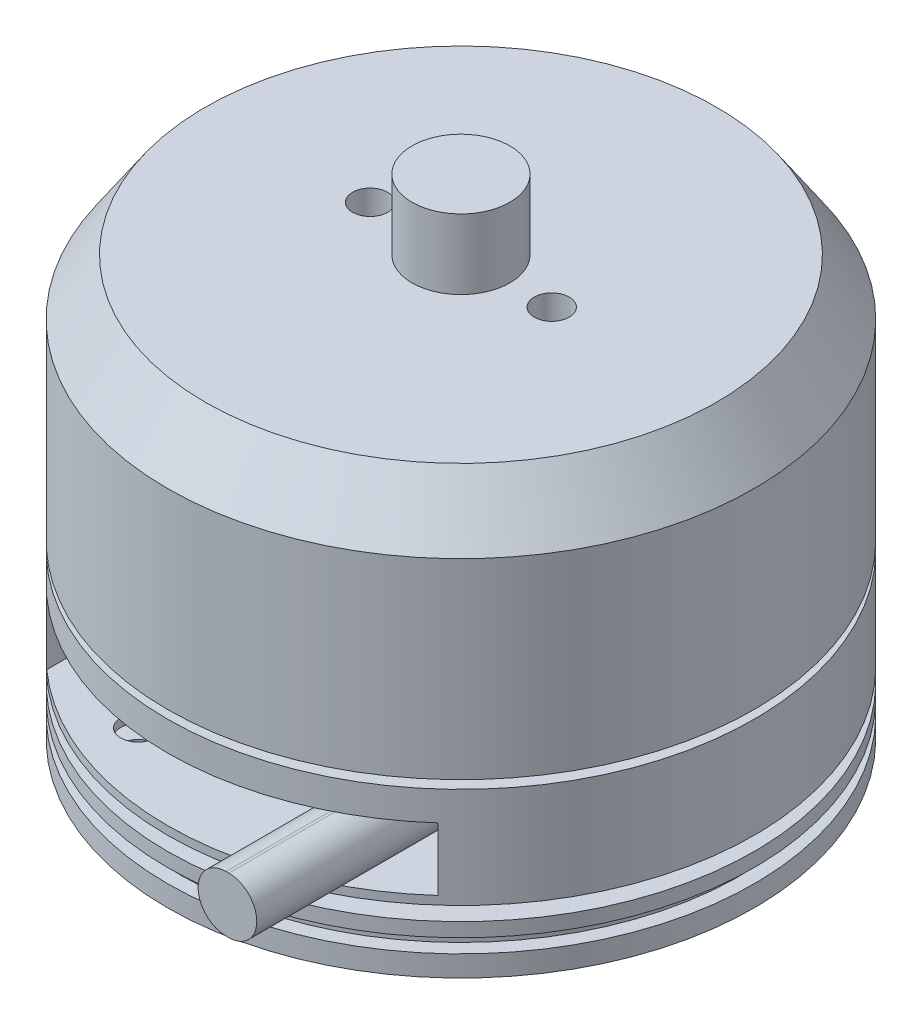
from build123d import *

# Parameters (mm, degrees)
SKETCH_2_W               = 28
SKETCH_2_H               = 4.5
CUT_EXTRUDE_1_DEPTH      = 10
EXTRUDE_1_DEPTH          = 15
HOLE_WIZARD_M3_1_D       = 2.5
HOLE_WIZARD_M3_1_DEPTH   = 4
HOLE_WIZARD_M3_1_TIP     = 0.751075774
CUT_EXTRUDE_2_DEPTH      = 20
HOLE_WIZARD_M4_1_D       = 3.3
HOLE_WIZARD_M4_1_DEPTH   = 10.1
HOLE_WIZARD_M4_1_TIP     = 0.991420021
HOLE_WIZARD_M3_2_D       = 2.5
HOLE_WIZARD_M5_1_D       = 4.2
HOLE_WIZARD_M5_1_DEPTH   = 14
HOLE_WIZARD_M5_1_TIP     = 1.2618073
SKETCH_17_W              = 73.774963695
SKETCH_17_H              = 83.233292373
CUT_EXTRUDE_3_DEPTH      = 22
CUT_EXTRUDE_3_DEPTH_BACK = 22
SKETCH_18_R              = 13.4
EXTRUDE_2_DEPTH          = 2
SKETCH_19_R              = 5.75
EXTRUDE_3_DEPTH          = 6.7
SKETCH_20_R              = 1.25
CUT_EXTRUDE_4_DEPTH      = 8


with BuildPart() as part:
    # 草图1 → 旋转1 (revolve)
    with BuildSketch(Plane.XY):
        Polygon((0, 0), (4.1, 0), (4.1, 6.7), (13.4, 6.7), (13.4, 8.7), (21, 8.7), (21, 10.2), (20, 10.2), (20, 11.2), (21, 11.2), (21, 12.2), (10, 12.2), (10, 13.2), (21, 13.2), (21, 20.4), (5, 20.4), (5, 21), (21, 21), (21, 34.7), (18.3, 38.7), (3.5, 38.7), (3.5, 43.7), (0, 43.7), align=None)
    revolve(axis=Axis((0, 43.7, 0), (0, -1, 0)))

    # 草图2 → 切除-拉伸1 (cut)
    with BuildSketch(Plane.XY.offset(21)):
        with Locations((0, 16.05)):
            Rectangle(SKETCH_2_W, SKETCH_2_H)
    extrude(amount=-CUT_EXTRUDE_1_DEPTH, mode=Mode.SUBTRACT)

    # 草图3 → 凸台-拉伸1 (add)
    with BuildSketch(Plane.XY.offset(11)):
        with BuildLine():
            Line((9.185056323, 18.053194417), (9.385056323, 18.053194417))
            ThreePointArc((9.385056323, 18.053194417), (11.385056323, 16.053194417), (9.385056323, 14.053194417))
            Line((9.385056323, 14.053194417), (9.185056323, 14.053194417))
            ThreePointArc((9.185056323, 14.053194417), (7.185056323, 16.053194417), (9.185056323, 18.053194417))
        make_face()
    extrude(amount=EXTRUDE_1_DEPTH)

    # M3 螺纹孔1
    with Locations(Plane(origin=(0, 38.7, 0), x_dir=(1, 0, 0), z_dir=(0, 1, 0))):
        with Locations((-6.5, 0), (6.5, 0)):
            Hole(HOLE_WIZARD_M3_1_D / 2, depth=HOLE_WIZARD_M3_1_DEPTH)
            with Locations((0, 0, -(HOLE_WIZARD_M3_1_DEPTH + HOLE_WIZARD_M3_1_TIP / 2))):  # 118° drill point
                Cone(0, HOLE_WIZARD_M3_1_D / 2, HOLE_WIZARD_M3_1_TIP, mode=Mode.SUBTRACT)

    # 草图7 → 旋转2 (revolve)
    with BuildSketch(Plane.XY):
        Polygon((0, -54.6), (5, -54.6), (5, -30.5), (8.275, -30.5), (8.275, -29.6), (13, -29.6), (13, -27.6), (21, -27.6), (21, 8.7), (0, 8.7), align=None)
    revolve(axis=Axis((0, 8.7, 0), (0, -1, 0)))

    # 草图8 → 切除-拉伸2 (cut)
    with BuildSketch(Plane.XZ.offset(54.6)):
        with BuildLine():
            Line((-3, 4), (3, 4))
            ThreePointArc((3, 4), (0, 5), (-3, 4))
        make_face()
    extrude(amount=-CUT_EXTRUDE_2_DEPTH, mode=Mode.SUBTRACT)

    # M4 螺纹孔1
    with Locations(Plane(origin=(0, -27.6, 0), x_dir=(-1, 0, 0), z_dir=(0, -1, 0))):
        with Locations((17.5, 0), (0, -17.5), (-17.5, 0), (0, 17.5)):
            Hole(HOLE_WIZARD_M4_1_D / 2, depth=HOLE_WIZARD_M4_1_DEPTH)
            with Locations((0, 0, -(HOLE_WIZARD_M4_1_DEPTH + HOLE_WIZARD_M4_1_TIP / 2))):  # 118° drill point
                Cone(0, HOLE_WIZARD_M4_1_D / 2, HOLE_WIZARD_M4_1_TIP, mode=Mode.SUBTRACT)

    # M3 螺纹孔2 (through all)
    with Locations(Plane(origin=(0, -44.6, 4), x_dir=(1, 0, 0), z_dir=(0, 0, 1))):
        with Locations((0, 0)):
            Hole(HOLE_WIZARD_M3_2_D / 2)

    # M5 螺纹孔1
    with Locations(Plane(origin=(0, -54.6, 0), x_dir=(-1, 0, 0), z_dir=(0, -1, 0))):
        with Locations((0, 0)):
            Hole(HOLE_WIZARD_M5_1_D / 2, depth=HOLE_WIZARD_M5_1_DEPTH)
            with Locations((0, 0, -(HOLE_WIZARD_M5_1_DEPTH + HOLE_WIZARD_M5_1_TIP / 2))):  # 118° drill point
                Cone(0, HOLE_WIZARD_M5_1_D / 2, HOLE_WIZARD_M5_1_TIP, mode=Mode.SUBTRACT)

    # 草图17 → 切除-拉伸3 (cut, two sides)
    with BuildSketch(Plane(origin=(0, 0, 0), x_dir=(0, 0, -1), z_dir=(1, 0, 0))) as cut_extrude_3_sk:
        with Locations((1.792626092, -32.916646187)):
            Rectangle(SKETCH_17_W, SKETCH_17_H)
    extrude(amount=CUT_EXTRUDE_3_DEPTH, mode=Mode.SUBTRACT)
    extrude(cut_extrude_3_sk.sketch, amount=-CUT_EXTRUDE_3_DEPTH_BACK, mode=Mode.SUBTRACT)

    # 草图18 → 凸台-拉伸2 (add)
    with BuildSketch(Plane.XZ.offset(-8.7)):
        Circle(SKETCH_18_R)
    extrude(amount=EXTRUDE_2_DEPTH)

    # 草图19 → 凸台-拉伸3 (add)
    with BuildSketch(Plane.XZ.offset(-6.7)):
        Circle(SKETCH_19_R)
    extrude(amount=EXTRUDE_3_DEPTH)

    # 草图20 → 切除-拉伸4 (cut)
    with BuildSketch(Plane.XZ.offset(-8.7)):
        with Locations((-7.117891254, 15.987045509)):
            Circle(SKETCH_20_R)
        with Locations((15.987045509, 7.117891254)):
            Circle(SKETCH_20_R)
        with Locations((7.117891254, -15.987045509)):
            Circle(SKETCH_20_R)
        with Locations((-15.987045509, -7.117891254)):
            Circle(SKETCH_20_R)
    extrude(amount=-CUT_EXTRUDE_4_DEPTH, mode=Mode.SUBTRACT)


solid = part.part
